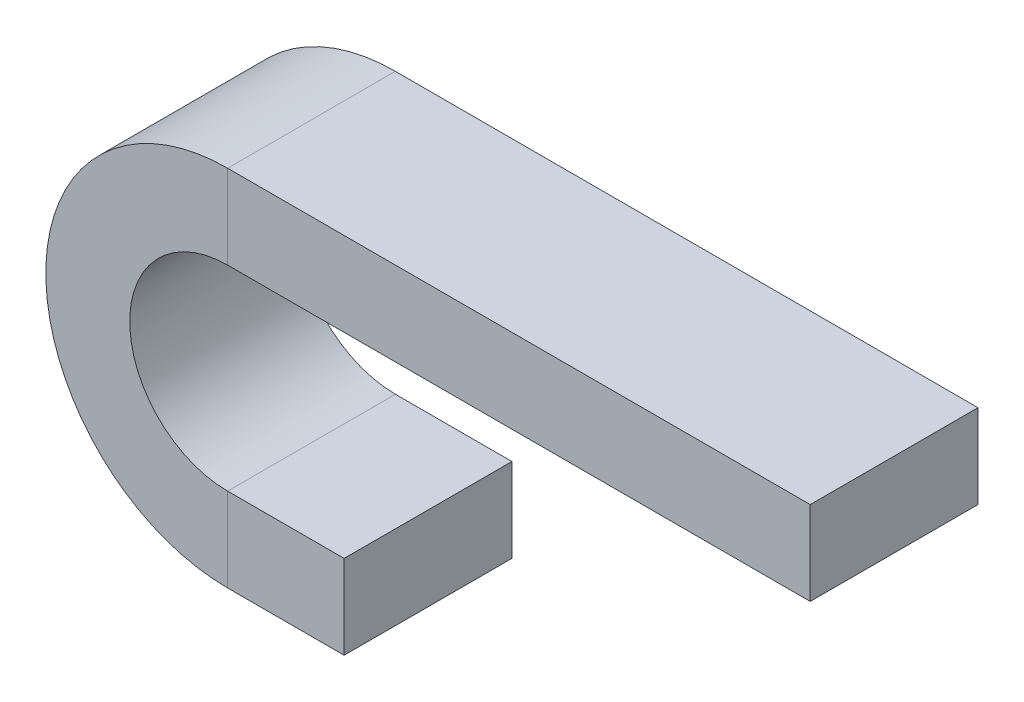
from build123d import *

# Parameters (mm, degrees)
SKETCH2_W = 72
SKETCH2_H = 36


with BuildPart() as part:
    # Sweep1: sweep along a path in Sketch1
    with BuildLine(Plane.XY) as sweep1_path:
        Line((0, 0), (-50, 0))
        ThreePointArc((-50, 0), (-110, 60), (-50, 120))
        Line((-50, 120), (200, 120))
    # Sketch2 → Sweep1 (sweep)
    with BuildSketch(Plane(origin=(0, 0, 0), x_dir=(0, 0, -1), z_dir=(1, 0, 0))):
        Rectangle(SKETCH2_W, SKETCH2_H)
    sweep(path=sweep1_path.line)


solid = part.part
